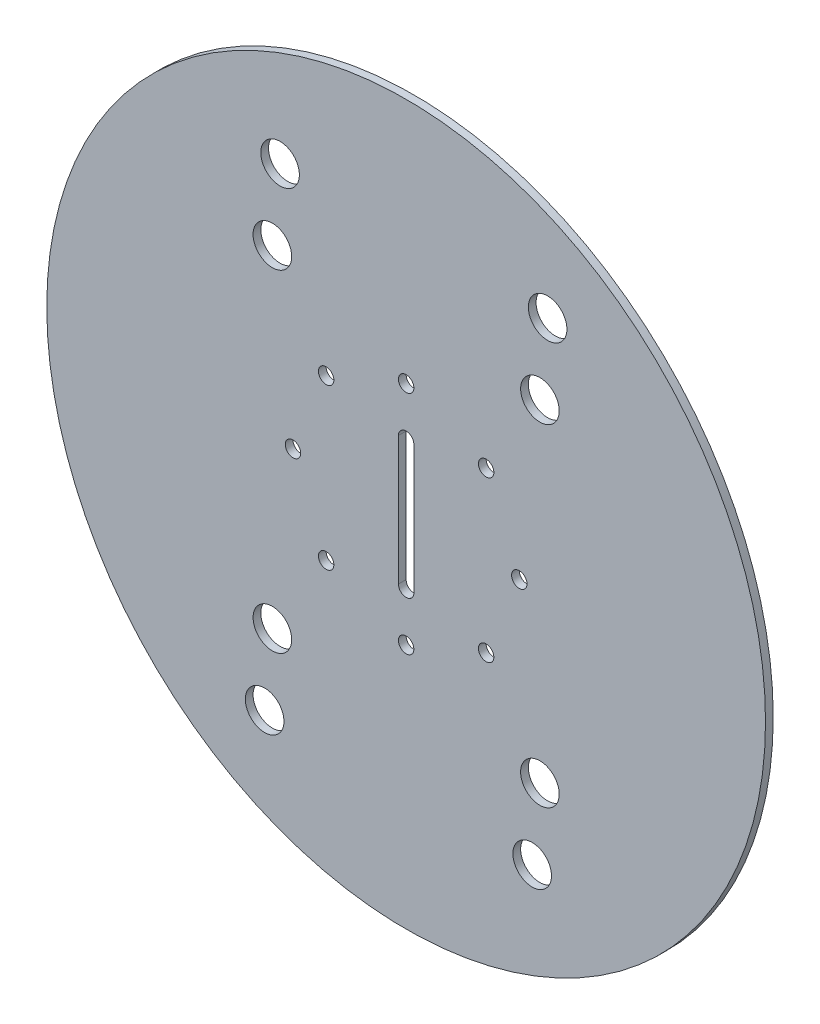
from build123d import *

# Parameters (mm, degrees)
SKETCH1_R           = 139.7
BOSS_EXTRUDE1_DEPTH = 3
SKETCH2_R           = 3
CUT_EXTRUDE1_DEPTH  = 4
SKETCH3_R           = 7.5
CUT_EXTRUDE2_DEPTH  = 4


with BuildPart() as part:
    # Sketch1 → Boss-Extrude1 (new body)
    with BuildSketch(Plane.XY):
        Circle(SKETCH1_R)
    extrude(amount=BOSS_EXTRUDE1_DEPTH)

    # Sketch2 → Cut-Extrude1 (cut, through all)
    with BuildSketch(Plane.XY.offset(3)):
        with Locations((0, 43.980361528)):
            Circle(SKETCH2_R)
        with Locations((31.098811876, 31.098811876)):
            Circle(SKETCH2_R)
        with Locations((43.980361528, 0)):
            Circle(SKETCH2_R)
        with Locations((31.098811876, -31.098811876)):
            Circle(SKETCH2_R)
        with Locations((0, -43.980361528)):
            Circle(SKETCH2_R)
        with Locations((-31.098811876, -31.098811876)):
            Circle(SKETCH2_R)
        with Locations((-43.980361528, 0)):
            Circle(SKETCH2_R)
        with Locations((-31.098811876, 31.098811876)):
            Circle(SKETCH2_R)
        with BuildLine():
            Line((-3, -25), (-3, 25))
            ThreePointArc((-3, 25), (0, 28), (3, 25))
            Line((3, 25), (3, -25))
            ThreePointArc((3, -25), (0, -28), (-3, -25))
        make_face()
    extrude(amount=-CUT_EXTRUDE1_DEPTH, mode=Mode.SUBTRACT)

    # Sketch3 → Cut-Extrude2 (cut, through all)
    with BuildSketch(Plane.XY.offset(3)):
        with Locations((-52, -64.5)):
            Circle(SKETCH3_R)
        with Locations((-55, -93.5)):
            Circle(SKETCH3_R)
        with Locations((52, 64.5)):
            Circle(SKETCH3_R)
        with Locations((55, 93.5)):
            Circle(SKETCH3_R)
        with Locations((52, -64.5)):
            Circle(SKETCH3_R)
        with Locations((49, -93.5)):
            Circle(SKETCH3_R)
        with Locations((-52, 64.5)):
            Circle(SKETCH3_R)
        with Locations((-49, 93.5)):
            Circle(SKETCH3_R)
    extrude(amount=-CUT_EXTRUDE2_DEPTH, mode=Mode.SUBTRACT)


solid = part.part
